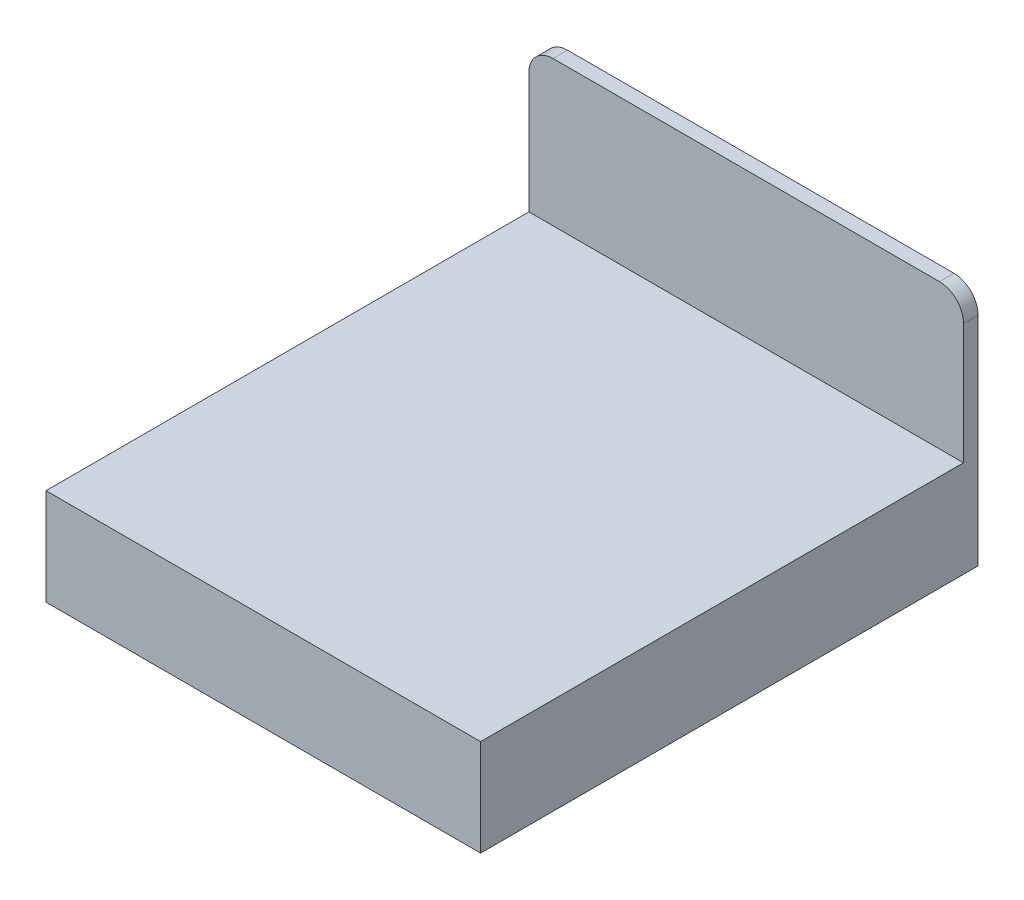
from build123d import *

# Parameters (mm, degrees)
SKETCH_1_W      = 1800
SKETCH_1_H      = 2000
EXTRUDE_1_DEPTH = 400
EXTRUDE_2_DEPTH = 60


with BuildPart() as part:
    # 草图1 → 凸台-拉伸1 (new body)
    with BuildSketch(Plane(origin=(0, 0, 0), x_dir=(1, 0, 0), z_dir=(0, 1, 0))):
        with Locations((-900, -1000)):
            Rectangle(SKETCH_1_W, SKETCH_1_H)
    extrude(amount=-EXTRUDE_1_DEPTH)

    # 草图2 → 凸台-拉伸2 (add)
    with BuildSketch(Plane(origin=(0, 0, 0), x_dir=(-1, 0, 0), z_dir=(0, 0, -1))):
        with BuildLine():
            Line((1800, -400), (1800, 500))
            ThreePointArc((1800, 500), (1770.710678119, 570.710678119), (1700, 600))
            Line((1700, 600), (100, 600))
            ThreePointArc((100, 600), (29.289321881, 570.710678119), (0, 500))
            Line((0, 500), (0, -400))
            Line((0, -400), (1800, -400))
        make_face()
    extrude(amount=EXTRUDE_2_DEPTH)


solid = part.part
